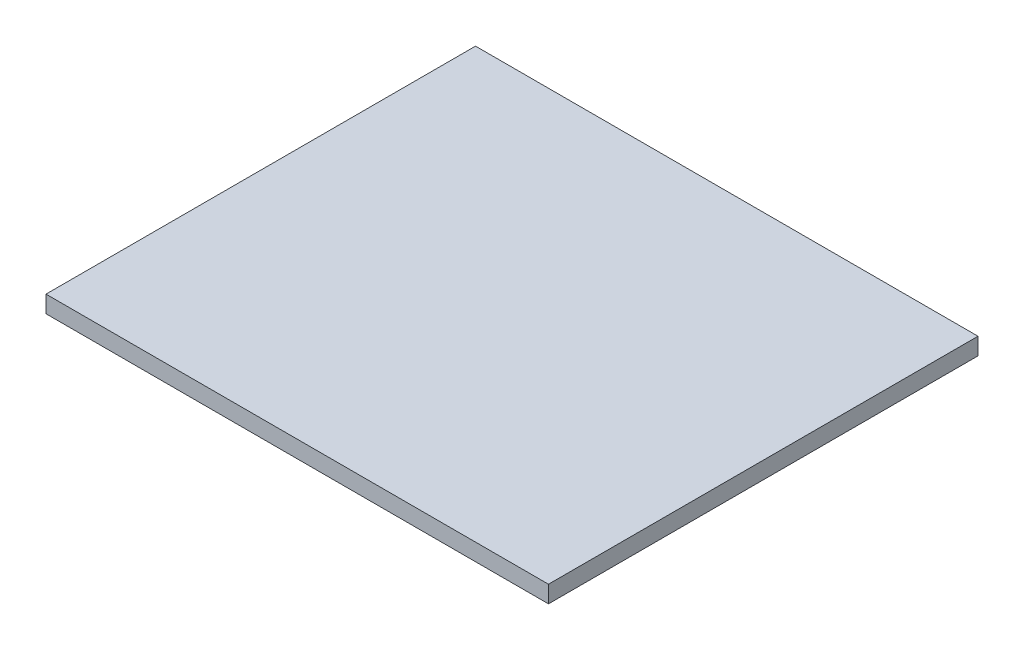
from build123d import *

# Parameters (mm, degrees)
SKETCH1_W           = 590
SKETCH1_H           = 504.35483871
BOSS_EXTRUDE1_DEPTH = 20


with BuildPart() as part:
    # Sketch1 → Boss-Extrude1 (new body)
    with BuildSketch(Plane(origin=(0, 0, 0), x_dir=(1, 0, 0), z_dir=(0, 1, 0))):
        with Locations((15, -12.822580645)):
            Rectangle(SKETCH1_W, SKETCH1_H)
    extrude(amount=BOSS_EXTRUDE1_DEPTH)


solid = part.part
